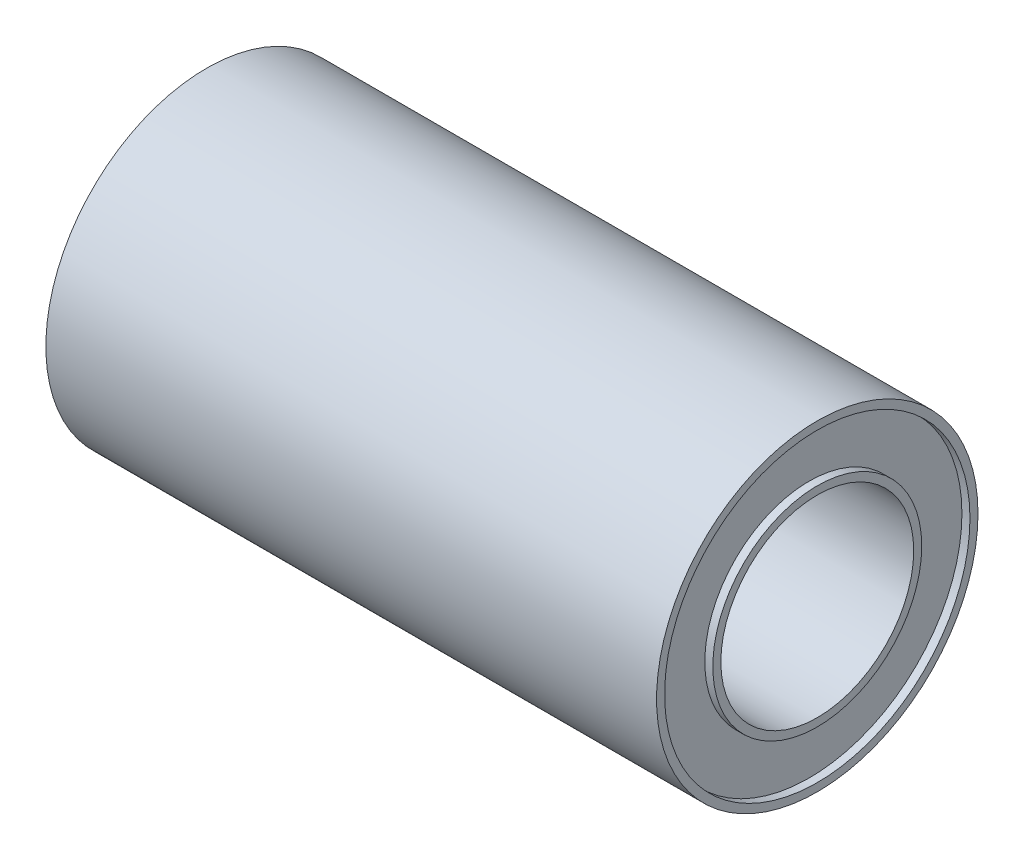
from build123d import *

# Parameters (mm, degrees)
SKETCH1_R          = 5
SKETCH1_R_2        = 3
EXTRUDE1_DEPTH     = 19
SKETCH2_R          = 4.75
SKETCH2_R_2        = 3.25
CUT_EXTRUDE1_DEPTH = 0.25


with BuildPart() as part:
    # Sketch1 → Extrude1 (new body)
    with BuildSketch(Plane(origin=(0, 0, 0), x_dir=(0, 0, -1), z_dir=(1, 0, 0))):
        Circle(SKETCH1_R)
        Circle(SKETCH1_R_2, mode=Mode.SUBTRACT)
    extrude(amount=EXTRUDE1_DEPTH)

    # Sketch2 → Cut-Extrude1 (cut)
    with BuildSketch(Plane(origin=(19, 0, 0), x_dir=(0, 0, -1), z_dir=(1, 0, 0))):
        Circle(SKETCH2_R)
        Circle(SKETCH2_R_2, mode=Mode.SUBTRACT)
    cut_extrude1 = extrude(amount=-CUT_EXTRUDE1_DEPTH, mode=Mode.SUBTRACT)

    # Mirror1: Cut-Extrude1 across plane
    add(cut_extrude1.mirror(Plane.ZY.offset(-9.5)), mode=Mode.SUBTRACT)


solid = part.part
